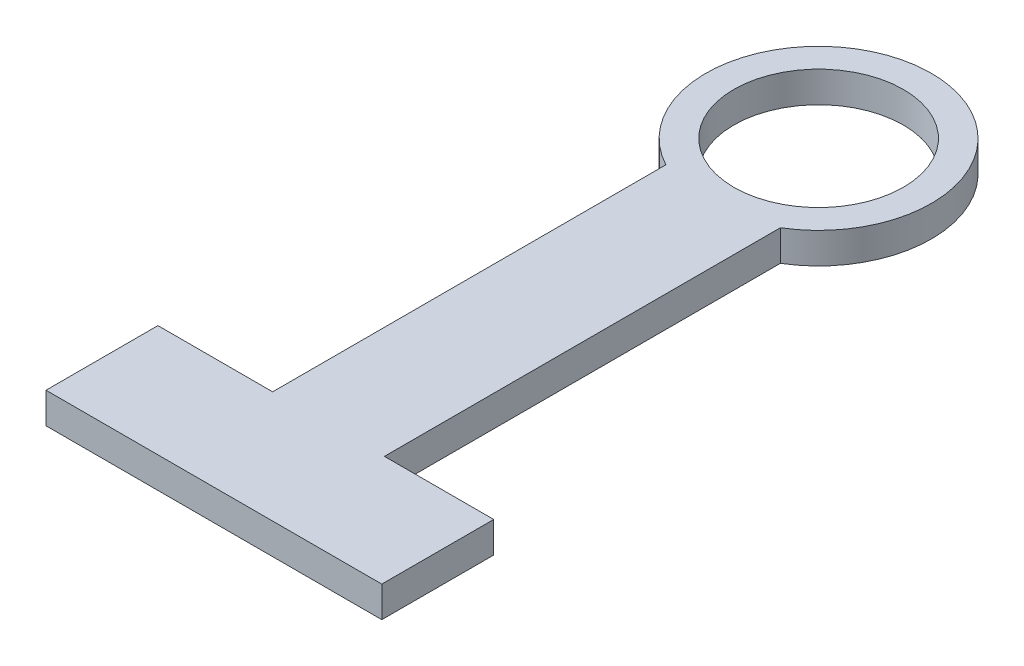
from build123d import *

# Parameters (mm, degrees)
SKETCH1_R           = 25.5905
SKETCH1_R_2         = 19.2405
BOSS_EXTRUDE1_DEPTH = 7


with BuildPart() as part:
    # Sketch1 → Boss-Extrude1 (new body)
    with BuildSketch(Plane(origin=(0, 0, 0), x_dir=(1, 0, 0), z_dir=(0, 1, 0))):
        Circle(SKETCH1_R)
        Circle(SKETCH1_R_2, mode=Mode.SUBTRACT)
        Polygon((-12.131390351, -20.018099484), (13.231279228, -20.018099484), (13.231279228, -111.76), (38.036054145, -111.76), (38.036054145, -137.16), (-38.163945855, -137.16), (-38.163945855, -111.76), (-12.131390351, -111.76), align=None)
    extrude(amount=BOSS_EXTRUDE1_DEPTH)


solid = part.part
